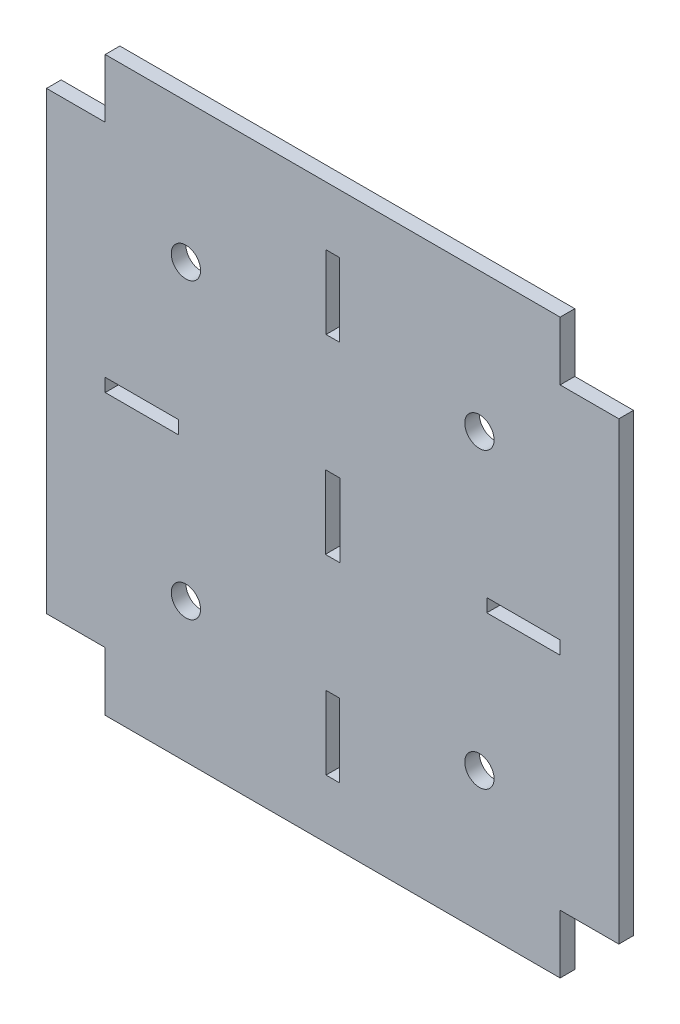
from build123d import *

# Parameters (mm, degrees)
SKETCH_1_R      = 2
SKETCH_1_W      = 1.8
SKETCH_1_H      = 10
SKETCH_1_W_2    = 10
SKETCH_1_H_2    = 1.8
SKETCH_1_W_3    = 2
EXTRUDE_1_DEPTH = 2


with BuildPart() as part:
    # 草圖1 → 填料-伸長1 (new body)
    with BuildSketch(Plane.XY):
        Polygon((-31, 39), (31, 39), (31, 31), (39, 31), (39, -31), (31, -31), (31, -39), (-31, -39), (-31, -31), (-39, -31), (-39, 31), (-31, 31), align=None)
        with Locations((-20, 20)):
            Circle(SKETCH_1_R, mode=Mode.SUBTRACT)
        with Locations((20, 20)):
            Circle(SKETCH_1_R, mode=Mode.SUBTRACT)
        with Locations((20, -20)):
            Circle(SKETCH_1_R, mode=Mode.SUBTRACT)
        with Locations((-20, -20)):
            Circle(SKETCH_1_R, mode=Mode.SUBTRACT)
        with Locations((0, -26)):
            Rectangle(SKETCH_1_W, SKETCH_1_H, mode=Mode.SUBTRACT)
        with Locations((0, 26)):
            Rectangle(SKETCH_1_W, SKETCH_1_H, mode=Mode.SUBTRACT)
        with Locations((-26, 0)):
            Rectangle(SKETCH_1_W_2, SKETCH_1_H_2, mode=Mode.SUBTRACT)
        with Locations((26, 0)):
            Rectangle(SKETCH_1_W_2, SKETCH_1_H_2, mode=Mode.SUBTRACT)
        Rectangle(SKETCH_1_W_3, SKETCH_1_H, mode=Mode.SUBTRACT)
    extrude(amount=EXTRUDE_1_DEPTH)


solid = part.part
